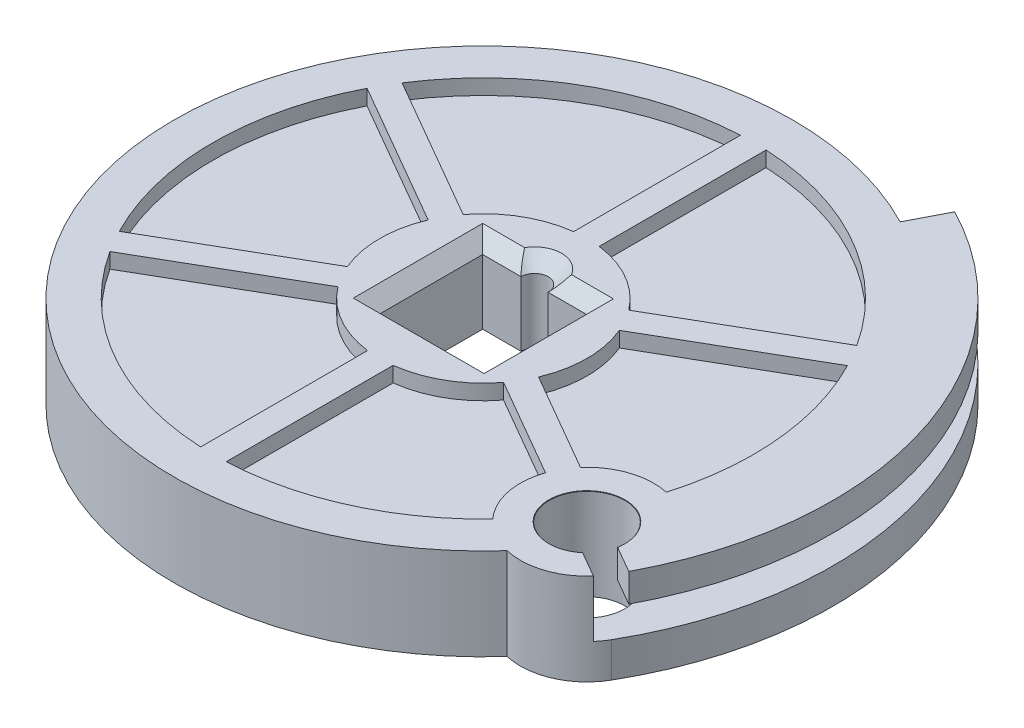
from build123d import *

# Parameters (mm, degrees)
ESBO_O1_R                              = 22.95
RESSALTO_EXTRUS_O1_DEPTH               = 3.4
ESBO_O2_R                              = 22.95
RESSALTO_EXTRUS_O2_DEPTH               = 2.266666667
CORTE_EXTRUS_O1_DEPTH                  = 7.8
CHANFRO1_SIZE                          = 1
RESSALTO_EXTRUS_O3_DEPTH               = 6.8
FURO_DE_DI_METRO_5_6_5_6_1_D           = 5.6
FURO_DE_DI_METRO_5_6_5_6_1_DEPTH       = 10
FURO_DE_DI_METRO_5_6_5_6_1_CSINK_D     = 5.65
FURO_DE_DI_METRO_5_6_5_6_1_CSINK_ANGLE = 90
FURO_DE_DI_METRO_5_6_5_6_1_TIP         = 1.682409733
ESBO_O8_W                              = 7.937144563
ESBO_O8_H                              = 2.1
CORTE_EXTRUS_O2_DEPTH                  = 4.2


with BuildPart() as part:
    # Esboço1 → Ressalto-extrusão1 (new body, symmetric)
    with BuildSketch(Plane(origin=(0, 0, 0), x_dir=(1, 0, 0), z_dir=(0, 1, 0))):
        Circle(ESBO_O1_R)
        with BuildLine():
            Line((-7.092448526, 2.997861554), (-17.819307423, 9.191016426))
            ThreePointArc((-17.819307423, 9.191016426), (-20.05, 0), (-17.819307423, -9.191016426))
            Line((-17.819307423, -9.191016426), (-7.092448526, -2.997861554))
            ThreePointArc((-7.092448526, -2.997861554), (-7.7, 0), (-7.092448526, 2.997861554))
        make_face(mode=Mode.SUBTRACT)
        with BuildLine():
            Line((-6.142448526, 4.643309822), (-16.869307423, 10.836464693))
            ThreePointArc((-16.869307423, 10.836464693), (-10.025, 17.363809346), (-0.95, 20.02748112))
            Line((-0.95, 20.02748112), (-0.95, 7.641171376))
            ThreePointArc((-0.95, 7.641171376), (-3.85, 6.668395609), (-6.142448526, 4.643309822))
        make_face(mode=Mode.SUBTRACT)
        with BuildLine():
            Line((0.95, 7.641171376), (0.95, 20.02748112))
            ThreePointArc((0.95, 20.02748112), (10.025, 17.363809346), (16.869307423, 10.836464693))
            Line((16.869307423, 10.836464693), (6.142448526, 4.643309822))
            ThreePointArc((6.142448526, 4.643309822), (3.85, 6.668395609), (0.95, 7.641171376))
        make_face(mode=Mode.SUBTRACT)
        with BuildLine():
            Line((7.092448526, 2.997861554), (17.819307423, 9.191016426))
            ThreePointArc((17.819307423, 9.191016426), (20.05, 0), (17.819307423, -9.191016426))
            Line((17.819307423, -9.191016426), (7.092448526, -2.997861554))
            ThreePointArc((7.092448526, -2.997861554), (7.7, 0), (7.092448526, 2.997861554))
        make_face(mode=Mode.SUBTRACT)
        with BuildLine():
            Line((6.142448526, -4.643309822), (16.869307423, -10.836464693))
            ThreePointArc((16.869307423, -10.836464693), (10.025, -17.363809346), (0.95, -20.02748112))
            Line((0.95, -20.02748112), (0.95, -7.641171376))
            ThreePointArc((0.95, -7.641171376), (3.85, -6.668395609), (6.142448526, -4.643309822))
        make_face(mode=Mode.SUBTRACT)
        with BuildLine():
            Line((-0.95, -7.641171376), (-0.95, -20.02748112))
            ThreePointArc((-0.95, -20.02748112), (-10.025, -17.363809346), (-16.869307423, -10.836464693))
            Line((-16.869307423, -10.836464693), (-6.142448526, -4.643309822))
            ThreePointArc((-6.142448526, -4.643309822), (-3.85, -6.668395609), (-0.95, -7.641171376))
        make_face(mode=Mode.SUBTRACT)
    extrude(amount=RESSALTO_EXTRUS_O1_DEPTH, both=True)

    # Esboço2 → Ressalto-extrusão2 (add)
    with BuildSketch(Plane(origin=(0, 0, 0), x_dir=(1, 0, 0), z_dir=(0, 1, 0))):
        Circle(ESBO_O2_R)
    extrude(amount=RESSALTO_EXTRUS_O2_DEPTH)

    # Esboço3 → Corte-extrusão1 (cut, through all)
    with BuildSketch(Plane(origin=(0, 3.4, 0), x_dir=(1, 0, 0), z_dir=(0, 1, 0))):
        with BuildLine():
            Line((1.00475453, 3.8), (3.85, 3.8))
            Line((3.85, 3.8), (3.85, -3.8))
            Line((3.85, -3.8), (-3.85, -3.8))
            Line((-3.85, -3.8), (-3.85, 3.8))
            Line((-3.85, 3.8), (-1.00475453, 3.8))
            ThreePointArc((-1.00475453, 3.8), (0, 4.80475453), (1.00475453, 3.8))
        make_face()
    extrude(amount=-CORTE_EXTRUS_O1_DEPTH, mode=Mode.SUBTRACT)

    # Chanfro1
    chanfro1_edges = [part.edges().sort_by_distance(p)[0] for p in [
        (3.85, -3.4, 0),
        (0, -3.4, 3.8),
        (-3.85, -3.4, 0),
        (-2.427377265, -3.4, -3.8),
        (0, -3.4, -4.80475453),
        (2.427377265, -3.4, -3.8),
        (3.85, 3.4, 0),
        (2.427377265, 3.4, -3.8),
        (0, 3.4, -4.80475453),
        (-2.427377265, 3.4, -3.8),
        (-3.85, 3.4, 0),
        (0, 3.4, 3.8),
    ]]
    chamfer(chanfro1_edges, length=CHANFRO1_SIZE)

    # Esboço4 → Ressalto-extrusão3 (add)
    with BuildSketch(Plane(origin=(0, 3.4, 0), x_dir=(1, 0, 0), z_dir=(0, 1, 0))):
        with BuildLine():
            Line((9.207366783, 17.810864576), (11.916766484, 23.05196687))
            ThreePointArc((11.916766484, 23.05196687), (24.902926978, 7.297035556), (22.473359228, -12.975))
            ThreePointArc((22.473359228, -12.975), (13.660702639, -12.504832962), (19.233912303, -5.66207714))
            ThreePointArc((19.233912303, -5.66207714), (18.438311669, 7.875986466), (9.207366783, 17.810864576))
        make_face()
    extrude(amount=-RESSALTO_EXTRUS_O3_DEPTH)

    # Furo de diâmetro Ø5.6 (5.6)1
    with Locations(Plane(origin=(0, 3.4, 0), x_dir=(1, 0, 0), z_dir=(0, 1, 0))):
        with Locations((18.186533479, -10.5)):
            CounterSinkHole(FURO_DE_DI_METRO_5_6_5_6_1_D / 2, FURO_DE_DI_METRO_5_6_5_6_1_CSINK_D / 2, depth=FURO_DE_DI_METRO_5_6_5_6_1_DEPTH, counter_sink_angle=FURO_DE_DI_METRO_5_6_5_6_1_CSINK_ANGLE)
            with Locations((0, 0, -(FURO_DE_DI_METRO_5_6_5_6_1_DEPTH + FURO_DE_DI_METRO_5_6_5_6_1_TIP / 2))):  # 118° drill point
                Cone(0, FURO_DE_DI_METRO_5_6_5_6_1_D / 2, FURO_DE_DI_METRO_5_6_5_6_1_TIP, mode=Mode.SUBTRACT)

    # Varredura de corte1: sweep along a path in Esboço7
    with BuildLine(Plane(origin=(0, 0, 0), x_dir=(1, 0, 0), z_dir=(0, 1, 0))) as varredura_de_corte1_path:
        ThreePointArc((19.875283017, -11.475), (19.875283017, 11.475), (0, 22.95))
    # Esboço8 → Varredura de corte1 (sweep, cut)
    with BuildSketch(Plane(origin=(0, 0, 0), x_dir=(0, 0, -1), z_dir=(1, 0, 0))):
        with Locations((26.918572282, 0.25)):
            Rectangle(ESBO_O8_W, ESBO_O8_H)
    sweep(path=varredura_de_corte1_path.line, mode=Mode.SUBTRACT)

    # Esboço9 → Corte-extrusão2 (cut)
    with BuildSketch(Plane(origin=(0, 3.4, 0), x_dir=(1, 0, 0), z_dir=(0, 1, 0))):
        Polygon((18.147037743, -11.574162637), (23.041410617, -14.399930134), (24.539064474, -13.070669968), (18.226029216, -9.425837363), align=None)
    extrude(amount=-CORTE_EXTRUS_O2_DEPTH, mode=Mode.SUBTRACT)


solid = part.part
